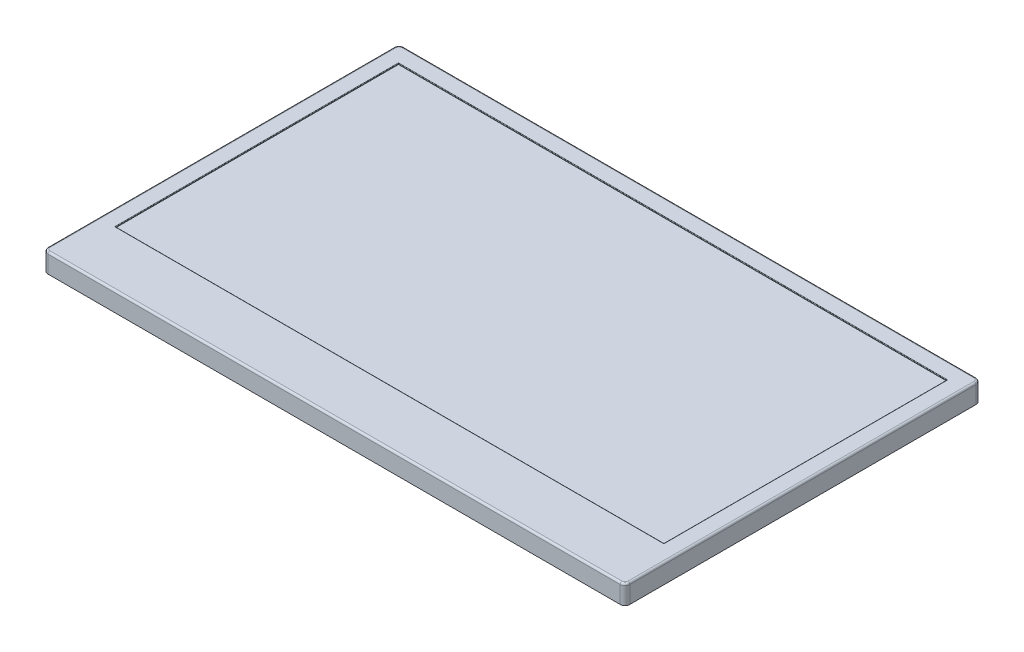
from build123d import *

# Parameters (mm, degrees)
SKETCH1_W           = 60.5
SKETCH1_H           = 37
BOSS_EXTRUDE1_DEPTH = 2
SKETCH2_W           = 57.01
SKETCH2_H           = 29.41
CUT_EXTRUDE1_DEPTH  = 0.1
FILLET1_R           = 0.5
FILLET2_R           = 0.2
FILLET3_R           = 0.05


with BuildPart() as part:
    # Sketch1 → Boss-Extrude1 (new body)
    with BuildSketch(Plane(origin=(0, 0, 0), x_dir=(1, 0, 0), z_dir=(0, 1, 0))):
        with Locations((30.25, 18.5)):
            Rectangle(SKETCH1_W, SKETCH1_H)
    extrude(amount=BOSS_EXTRUDE1_DEPTH)

    # Sketch2 → Cut-Extrude1 (cut)
    with BuildSketch(Plane(origin=(0, 2, 0), x_dir=(1, 0, 0), z_dir=(0, 1, 0))):
        with Locations((30.25, 20.495)):
            Rectangle(SKETCH2_W, SKETCH2_H)
    extrude(amount=-CUT_EXTRUDE1_DEPTH, mode=Mode.SUBTRACT)

    # Fillet1
    fillet1_edges = [part.edges().sort_by_distance(p)[0] for p in [
        (0, 1, 0),
        (60.5, 1, 0),
        (60.5, 1, -37),
        (0, 1, -37),
    ]]
    fillet(fillet1_edges, radius=FILLET1_R)

    # Fillet2
    fillet2_edges = [part.edges().sort_by_distance(p)[0] for p in [
        (30.25, 2, 0),
        (0, 2, -18.5),
        (60.5, 2, -18.5),
        (30.25, 2, -37),
        (0.146446609, 2, -36.853553391),
        (60.353553391, 2, -36.853553391),
        (60.353553391, 2, -0.146446609),
        (0.146446609, 2, -0.146446609),
    ]]
    fillet(fillet2_edges, radius=FILLET2_R)

    # Fillet3
    fillet3_edges = [part.edges().sort_by_distance(p)[0] for p in [
        (1.745, 2, -20.495),
        (30.25, 2, -5.79),
        (58.755, 2, -20.495),
        (30.25, 2, -35.2),
    ]]
    fillet(fillet3_edges, radius=FILLET3_R)


solid = part.part
